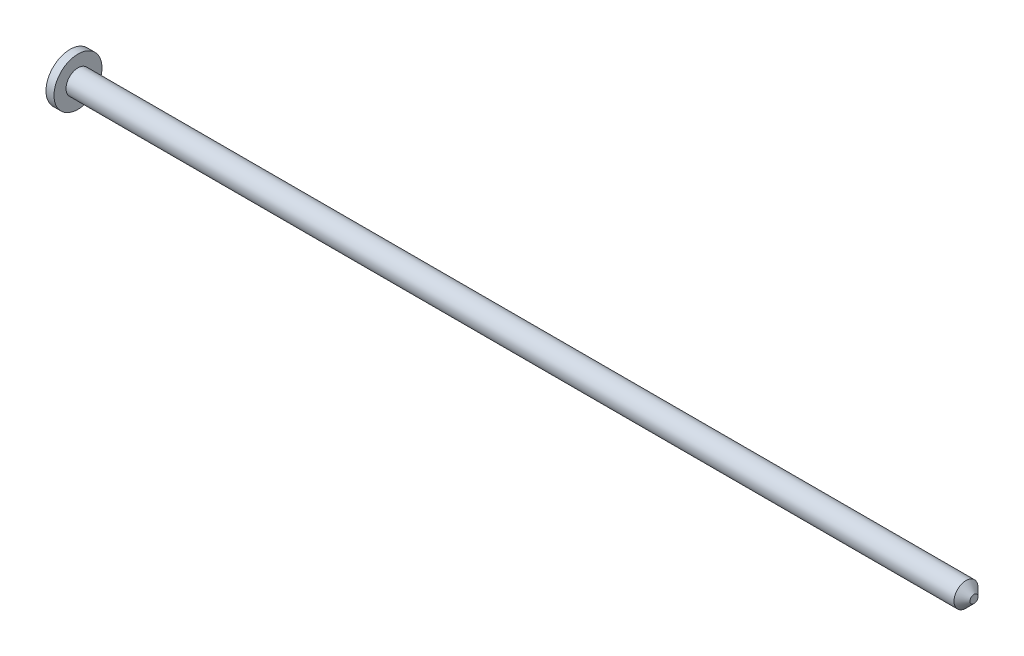
from build123d import *

# Parameters (mm, degrees)
CHAMFER1_SIZE = 1


with BuildPart() as part:
    # Sketch1 → Revolve1 (revolve)
    with BuildSketch(Plane.XY):
        Polygon((0, 0), (113, 0), (113, 1.5), (1, 1.5), (1, 3), (0, 3), align=None)
    revolve(axis=Axis((0, 0, 0), (1, 0, 0)))

    # Chamfer1
    chamfer1_edges = [part.edges().sort_by_distance(p)[0] for p in [
        (113, -1.5, 0),
    ]]
    chamfer(chamfer1_edges, length=CHAMFER1_SIZE)


solid = part.part
